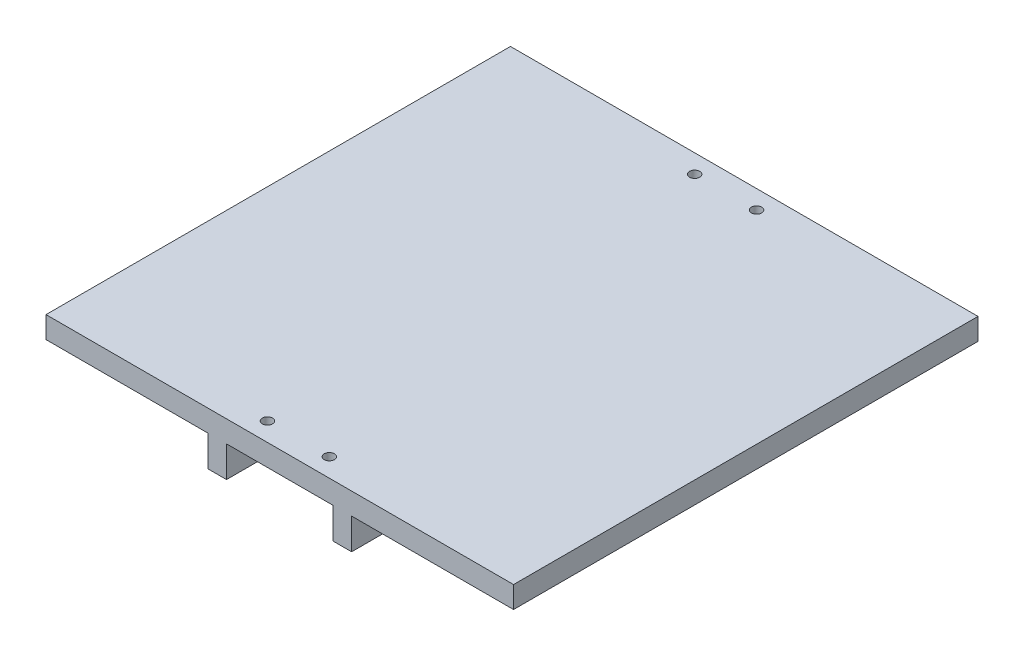
from build123d import *

# Parameters (mm, degrees)
BOSS_EXTRUDE1_DEPTH = 150
SKETCH4_R           = 1.65
CUT_EXTRUDE1_DEPTH  = 7


with BuildPart() as part:
    # Sketch1 → Boss-Extrude1 (new body)
    with BuildSketch(Plane.XY):
        Polygon((-75.5, 3.5), (75.5, 3.5), (75.5, -3.5), (23.2, -3.5), (23.2, -13.5), (17.2, -13.5), (17.2, -3.5), (-17.2, -3.5), (-17.2, -13.5), (-23.2, -13.5), (-23.2, -3.5), (-75.5, -3.5), align=None)
    extrude(amount=BOSS_EXTRUDE1_DEPTH)

    # Sketch4 → Cut-Extrude1 (cut)
    with BuildSketch(Plane.XZ.offset(3.5)):
        with Locations((-10, 6)):
            Circle(SKETCH4_R)
        with Locations((10, 6)):
            Circle(SKETCH4_R)
        with Locations((-10, 144)):
            Circle(SKETCH4_R)
        with Locations((10, 144)):
            Circle(SKETCH4_R)
    extrude(amount=-CUT_EXTRUDE1_DEPTH, mode=Mode.SUBTRACT)


solid = part.part
